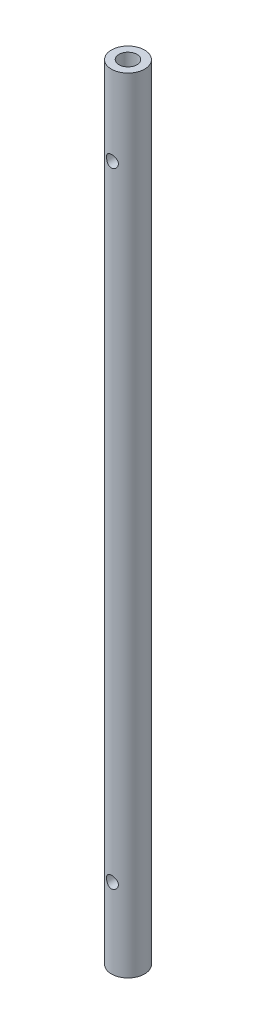
from build123d import *

# Parameters (mm, degrees)
SKETCH1_R                 = 3.175
BOSS_EXTRUDE1_DEPTH       = 149.86
F_8_32_TAPPED_HOLE1_D     = 3.4544
F_8_32_TAPPED_HOLE1_DEPTH = 12.7
F_8_32_TAPPED_HOLE1_TIP   = 1.037806461
F_8_32_TAPPED_HOLE2_D     = 3.4544
F_8_32_TAPPED_HOLE2_DEPTH = 15.0876
F_8_32_TAPPED_HOLE2_TIP   = 1.037806461
SKETCH6_R                 = 1.1303
CUT_EXTRUDE1_DEPTH        = 4.175
CUT_EXTRUDE1_DEPTH_BACK   = 4.175


with BuildPart() as part:
    # Sketch1 → Boss-Extrude1 (new body)
    with BuildSketch(Plane(origin=(0, 0, 0), x_dir=(1, 0, 0), z_dir=(0, 1, 0))):
        Circle(SKETCH1_R)
    extrude(amount=BOSS_EXTRUDE1_DEPTH)

    # #8-32 Tapped Hole1
    with Locations(Plane(origin=(0, 0, 0), x_dir=(-1, 0, 0), z_dir=(0, -1, 0))):
        with Locations((0, 0)):
            Hole(F_8_32_TAPPED_HOLE1_D / 2, depth=F_8_32_TAPPED_HOLE1_DEPTH)
            with Locations((0, 0, -(F_8_32_TAPPED_HOLE1_DEPTH + F_8_32_TAPPED_HOLE1_TIP / 2))):  # 118° drill point
                Cone(0, F_8_32_TAPPED_HOLE1_D / 2, F_8_32_TAPPED_HOLE1_TIP, mode=Mode.SUBTRACT)

    # #8-32 Tapped Hole2
    with Locations(Plane(origin=(0, 149.86, 0), x_dir=(1, 0, 0), z_dir=(0, 1, 0))):
        with Locations((0, 0)):
            Hole(F_8_32_TAPPED_HOLE2_D / 2, depth=F_8_32_TAPPED_HOLE2_DEPTH)
            with Locations((0, 0, -(F_8_32_TAPPED_HOLE2_DEPTH + F_8_32_TAPPED_HOLE2_TIP / 2))):  # 118° drill point
                Cone(0, F_8_32_TAPPED_HOLE2_D / 2, F_8_32_TAPPED_HOLE2_TIP, mode=Mode.SUBTRACT)

    # Sketch6 → Cut-Extrude1 (cut, two sides)
    with BuildSketch(Plane.XY) as cut_extrude1_sk:
        with Locations((0, 134.62)):
            Circle(SKETCH6_R)
        with Locations((0, 15.24)):
            Circle(SKETCH6_R)
    extrude(amount=CUT_EXTRUDE1_DEPTH, mode=Mode.SUBTRACT)
    extrude(cut_extrude1_sk.sketch, amount=-CUT_EXTRUDE1_DEPTH_BACK, mode=Mode.SUBTRACT)


solid = part.part
